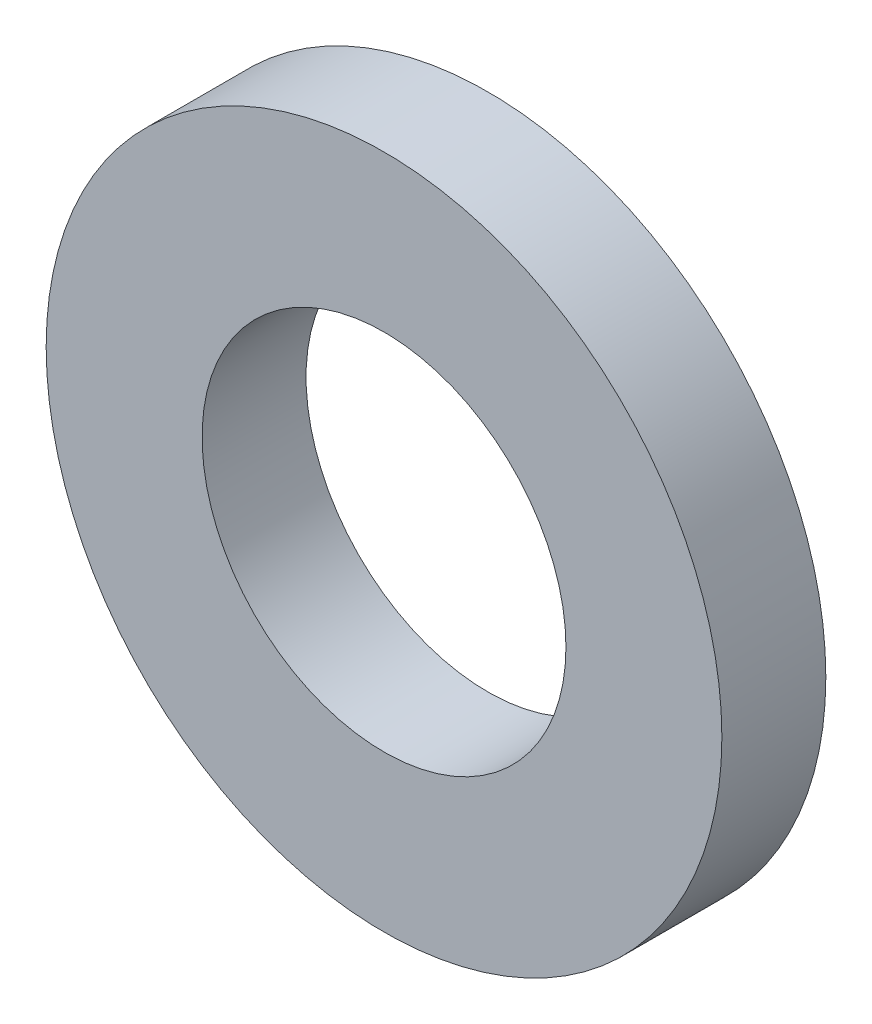
from build123d import *

# Parameters (mm, degrees)
SKETCH1_R           = 13
SKETCH1_R_2         = 7
BOSS_EXTRUDE1_DEPTH = 4


with BuildPart() as part:
    # Sketch1 → Boss-Extrude1 (new body)
    with BuildSketch(Plane.XY):
        Circle(SKETCH1_R)
        Circle(SKETCH1_R_2, mode=Mode.SUBTRACT)
    extrude(amount=BOSS_EXTRUDE1_DEPTH)


solid = part.part
